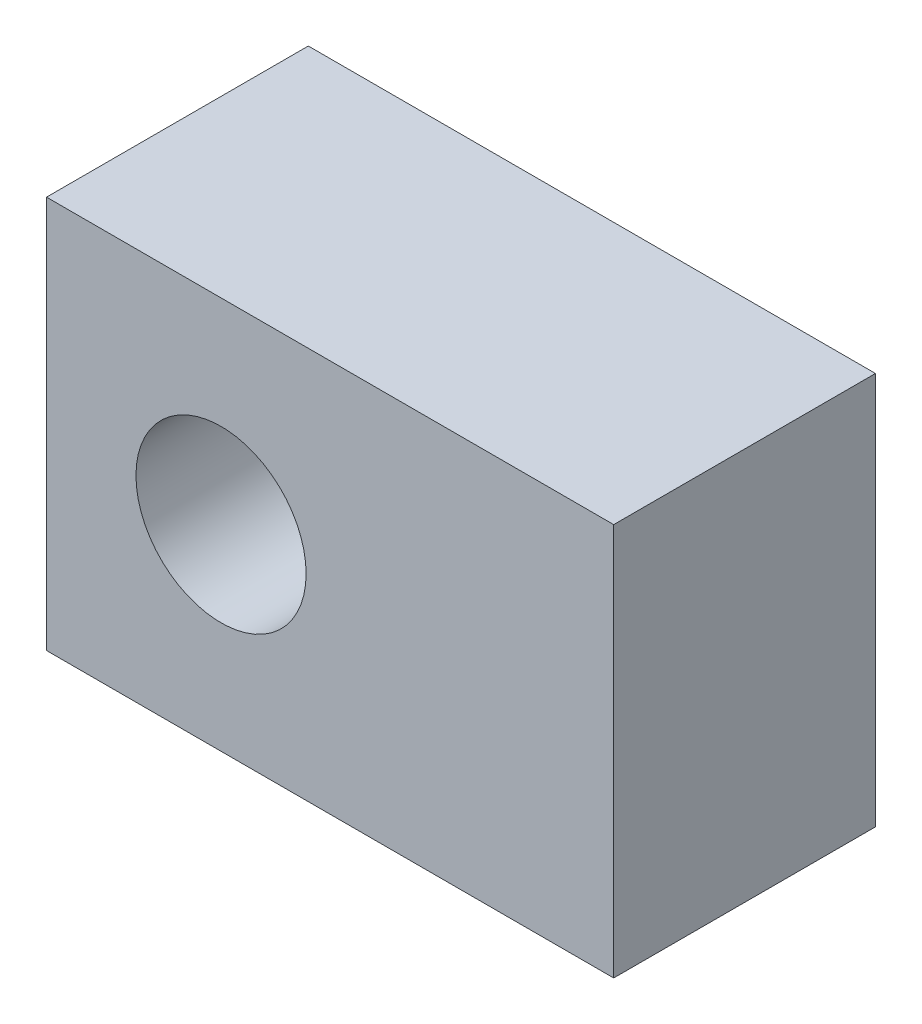
from build123d import *

# Parameters (mm, degrees)
SKETCH1_W      = 13
SKETCH1_H      = 9
EXTRUDE1_DEPTH = 6
SKETCH2_R      = 1.95
EXTRUDE2_DEPTH = 16


with BuildPart() as part:
    # Sketch1 → Extrude1 (new body)
    with BuildSketch(Plane.XY):
        with Locations((-8.345632515, 4.323347627)):
            Rectangle(SKETCH1_W, SKETCH1_H)
    extrude(amount=EXTRUDE1_DEPTH)

    # Sketch2 → Extrude2 (cut)
    with BuildSketch(Plane.XY.offset(6)):
        with Locations((-10.845632515, 4.323347627)):
            Circle(SKETCH2_R)
    extrude(amount=-EXTRUDE2_DEPTH, mode=Mode.SUBTRACT)


solid = part.part
